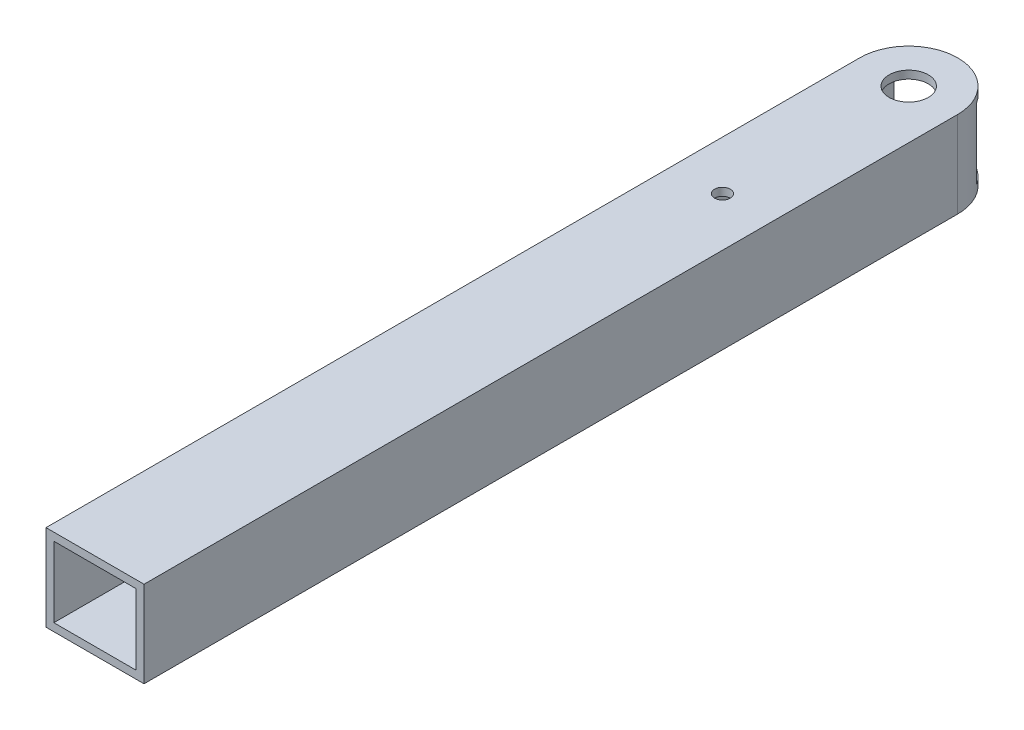
from build123d import *

# Parameters (mm, degrees)
SZKIC1_W                          = 25
SZKIC1_H                          = 22
SZKIC1_W_2                        = 21
SZKIC1_H_2                        = 18
WYCI_GNI_CIE_CIENKA_CIANKA1_DEPTH = 220
WYTNIJ_WYCI_GNI_CIE1_DEPTH        = 23
SZKIC3_R                          = 5
WYTNIJ_WYCI_GNI_CIE2_DEPTH        = 23
SZKIC4_R                          = 2
WYTNIJ_WYCI_GNI_CIE3_DEPTH        = 23


with BuildPart() as part:
    # Szkic1 → Wyciągnięcie-cienka ścianka1 (new body)
    with BuildSketch(Plane.XY):
        with Locations((12.5, -9.5)):
            Rectangle(SZKIC1_W, SZKIC1_H)
        with Locations((12.5, -9.5)):
            Rectangle(SZKIC1_W_2, SZKIC1_H_2, mode=Mode.SUBTRACT)
    extrude(amount=WYCI_GNI_CIE_CIENKA_CIANKA1_DEPTH)

    # Szkic2 → Wytnij-wyciągnięcie1 (cut, through all)
    with BuildSketch(Plane.XZ.offset(20.5)):
        with BuildLine():
            ThreePointArc((12.5, 0), (3.661165235, 3.661165235), (0, 12.5))
            Line((0, 12.5), (0, 0))
            Line((0, 0), (12.5, 0))
        make_face()
        with BuildLine():
            ThreePointArc((25, 12.5), (21.338834765, 3.661165235), (12.5, 0))
            Line((12.5, 0), (25, 0))
            Line((25, 0), (25, 12.5))
        make_face()
    extrude(amount=-WYTNIJ_WYCI_GNI_CIE1_DEPTH, mode=Mode.SUBTRACT)

    # Szkic3 → Wytnij-wyciągnięcie2 (cut, through all)
    with BuildSketch(Plane.XZ.offset(20.5)):
        with Locations((12.5, 12.5)):
            Circle(SZKIC3_R)
    extrude(amount=-WYTNIJ_WYCI_GNI_CIE2_DEPTH, mode=Mode.SUBTRACT)

    # Szkic4 → Wytnij-wyciągnięcie3 (cut, through all)
    with BuildSketch(Plane.XZ.offset(20.5)):
        with Locations((12.5, 60)):
            Circle(SZKIC4_R)
    extrude(amount=-WYTNIJ_WYCI_GNI_CIE3_DEPTH, mode=Mode.SUBTRACT)


solid = part.part
